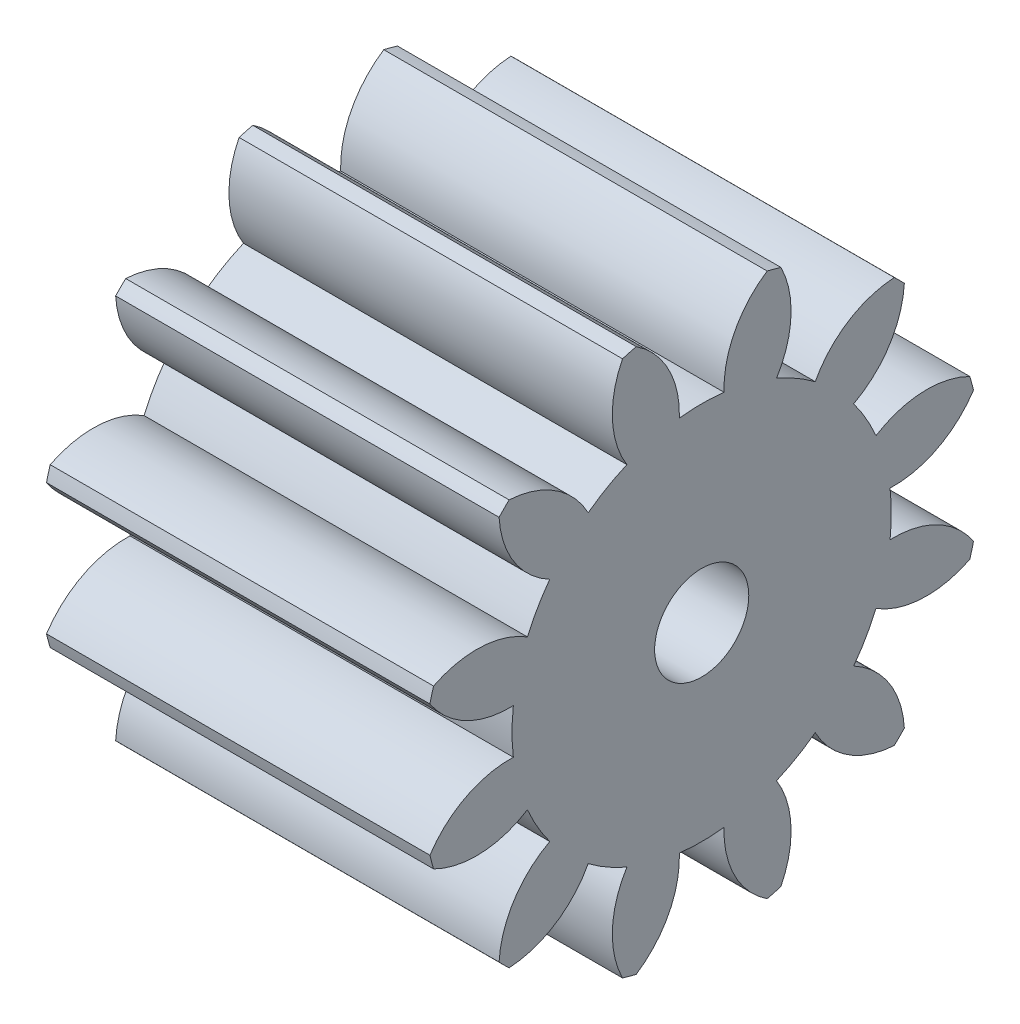
from build123d import *

# Parameters (mm, degrees)
BASPROSKE_W        = 12
BASPROSKE_H        = 8.75
TOOTHCUT_DEPTH     = 18.237314176
TEETHCUTS_COUNT    = 12
TEETHCUTS_ANGLE    = 330
BORSKE_R           = 0.4
BORE_DEPTH         = 50.0000508
SKETCH3_R          = 1.4732
CUT_EXTRUDE1_DEPTH = 17.991923373


with BuildPart() as part:
    # BasProSke → Base-Revolve (revolve)
    with BuildSketch(Plane(origin=(0, 0, 0), x_dir=(1, 0, 0), z_dir=(0, 1, 0)), mode=Mode.PRIVATE) as base_revolve_sk:
        with Locations((6, 4.375)):
            Rectangle(BASPROSKE_W, BASPROSKE_H)
    revolve(base_revolve_sk.sketch.rotate(Axis((-10, 0, 0), (1, 0, 0)), 180), axis=Axis((-10, 0, 0), (1, 0, 0)))

    # TooCutSke → ToothCut (cut, through all)
    with BuildSketch(Plane(origin=(0, 0, 0), x_dir=(0, 0, -1), z_dir=(1, 0, 0))):
        with BuildLine():
            ThreePointArc((0.699286786, 5.895170077), (0, 5.9365), (-0.699286786, 5.895170077))
            ThreePointArc((-0.699286786, 5.895170077), (-1.040581249, 7.393099844), (-2.078649209, 8.525659073))
            ThreePointArc((-2.078649209, 8.525659073), (0, 8.7754), (2.078649209, 8.525659073))
            ThreePointArc((2.078649209, 8.525659073), (1.040581249, 7.393099844), (0.699286786, 5.895170077))
        make_face()
    toothcut = extrude(amount=TOOTHCUT_DEPTH, mode=Mode.SUBTRACT)

    # TeethCuts: ToothCut ×12 about axis
    teethcuts_axis = Axis((-10, 0, 0), (1, 0, 0))
    for i in range(1, TEETHCUTS_COUNT):
        add(toothcut.rotate(teethcuts_axis, i * TEETHCUTS_ANGLE / (TEETHCUTS_COUNT - 1)), mode=Mode.SUBTRACT)

    # BorSke → Bore (cut, symmetric)
    with BuildSketch(Plane(origin=(0, 0, 0), x_dir=(0, 0, -1), z_dir=(1, 0, 0))):
        with Locations(Location((0, 0, 0), (0, 0, 180))):
            Circle(BORSKE_R)
    extrude(amount=BORE_DEPTH, both=True, mode=Mode.SUBTRACT)

    # Sketch3 → Cut-Extrude1 (cut, through all)
    with BuildSketch(Plane(origin=(12, 0, 0), x_dir=(0, 0, -1), z_dir=(1, 0, 0))):
        Circle(SKETCH3_R)
    extrude(amount=-CUT_EXTRUDE1_DEPTH, mode=Mode.SUBTRACT)


solid = part.part
